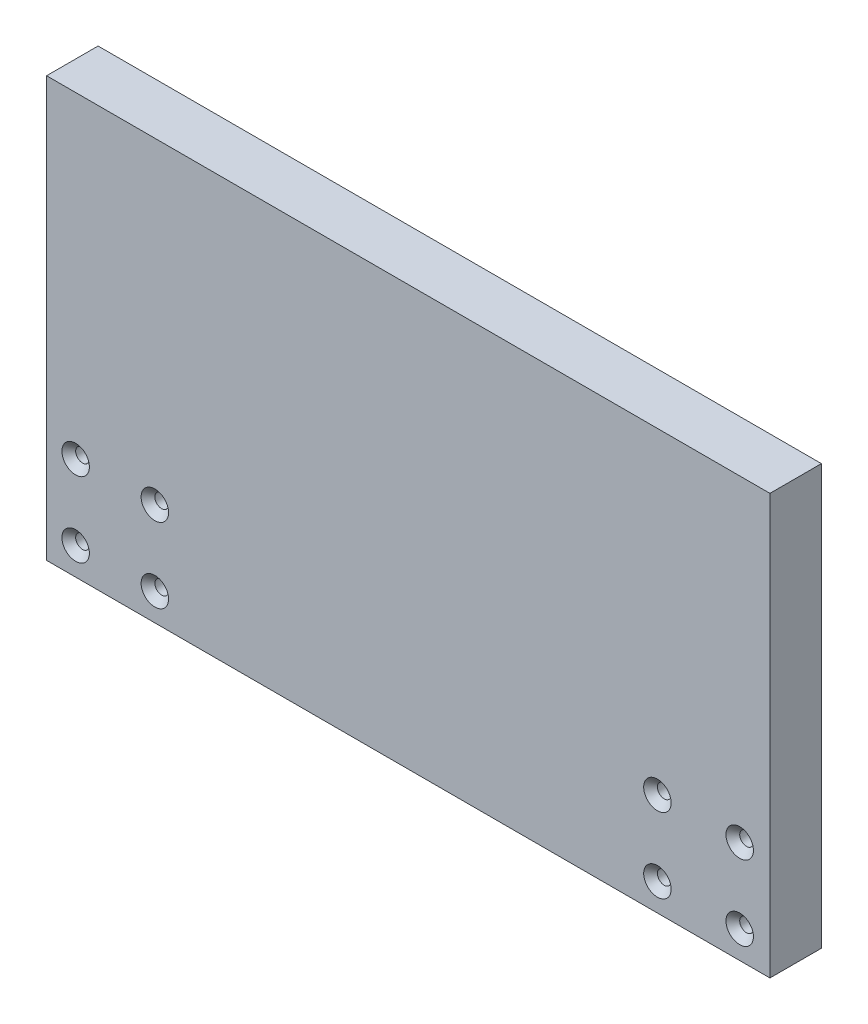
from build123d import *

# Parameters (mm, degrees)
SKETCH2_W               = 334.5
SKETCH2_H               = 194.1
PRIMARY_EXTRUSION_DEPTH = 25.4
RAIL_START              = -25.4
RAIL_MOUNTING_DEPTH     = 10
SKETCH3_R               = 3.175
CUT_EXTRUDE2_DEPTH      = 26.4
CHAMFER1_SIZE           = 3.175
CHAMFER2_SIZE           = 1.5875


with BuildPart() as part:
    # Sketch2 → Primary Extrusion (new body)
    with BuildSketch(Plane.XY):
        with Locations((-21.625, 97.05)):
            Rectangle(SKETCH2_W, SKETCH2_H)
    extrude(amount=-PRIMARY_EXTRUSION_DEPTH)

    # Sketch2_3 → Rail Mounting (cut)
    with BuildSketch(Plane.XY.offset(RAIL_START)):
        with BuildLine():
            ThreePointArc((-112.875, 31.75), (-114.625, 30), (-112.875, 28.25))
            ThreePointArc((-112.875, 28.25), (-111.125, 30), (-112.875, 31.75))
        make_face()
        with BuildLine():
            ThreePointArc((-52.875, 31.75), (-54.625, 30), (-52.875, 28.25))
            ThreePointArc((-52.875, 28.25), (-51.125, 30), (-52.875, 31.75))
        make_face()
        with BuildLine():
            ThreePointArc((7.125, 31.75), (5.375, 30), (7.125, 28.25))
            ThreePointArc((7.125, 28.25), (8.875, 30), (7.125, 31.75))
        make_face()
        with BuildLine():
            ThreePointArc((67.125, 31.75), (65.375, 30), (67.125, 28.25))
            ThreePointArc((67.125, 28.25), (68.875, 30), (67.125, 31.75))
        make_face()
    extrude(amount=RAIL_MOUNTING_DEPTH, mode=Mode.SUBTRACT)

    # Sketch3 → Cut-Extrude2 (cut, through all)
    with BuildSketch(Plane.XY):
        with Locations((-138.815833333, 47.3)):
            Circle(SKETCH3_R)
        with Locations((-138.815833333, 12.7)):
            Circle(SKETCH3_R)
        with Locations((93.595, 47.3)):
            Circle(SKETCH3_R)
        with Locations((131.655, 47.3)):
            Circle(SKETCH3_R)
        with Locations((131.655, 12.7)):
            Circle(SKETCH3_R)
        with Locations((93.595, 12.7)):
            Circle(SKETCH3_R)
        with Locations((-175.434166667, 12.7)):
            Circle(SKETCH3_R)
        with Locations((-175.434166667, 47.3)):
            Circle(SKETCH3_R)
    extrude(amount=-CUT_EXTRUDE2_DEPTH, mode=Mode.SUBTRACT)

    # Chamfer1
    chamfer1_edges = [part.edges().sort_by_distance(p)[0] for p in [
        (128.48, 12.7, 0),
        (90.42, 47.3, 0),
        (128.48, 47.3, 0),
        (-141.990833333, 12.7, 0),
        (90.42, 12.7, 0),
        (-178.609166667, 12.7, 0),
        (-178.609166667, 47.3, 0),
        (-141.990833333, 47.3, 0),
    ]]
    chamfer(chamfer1_edges, length=CHAMFER1_SIZE)

    # Chamfer2
    chamfer2_edges = [part.edges().sort_by_distance(p)[0] for p in [
        (-21.625, 0, -25.4),
        (145.625, 97.05, -25.4),
        (-21.625, 194.1, -25.4),
        (-188.875, 97.05, -25.4),
    ]]
    chamfer(chamfer2_edges, length=CHAMFER2_SIZE)


solid = part.part
